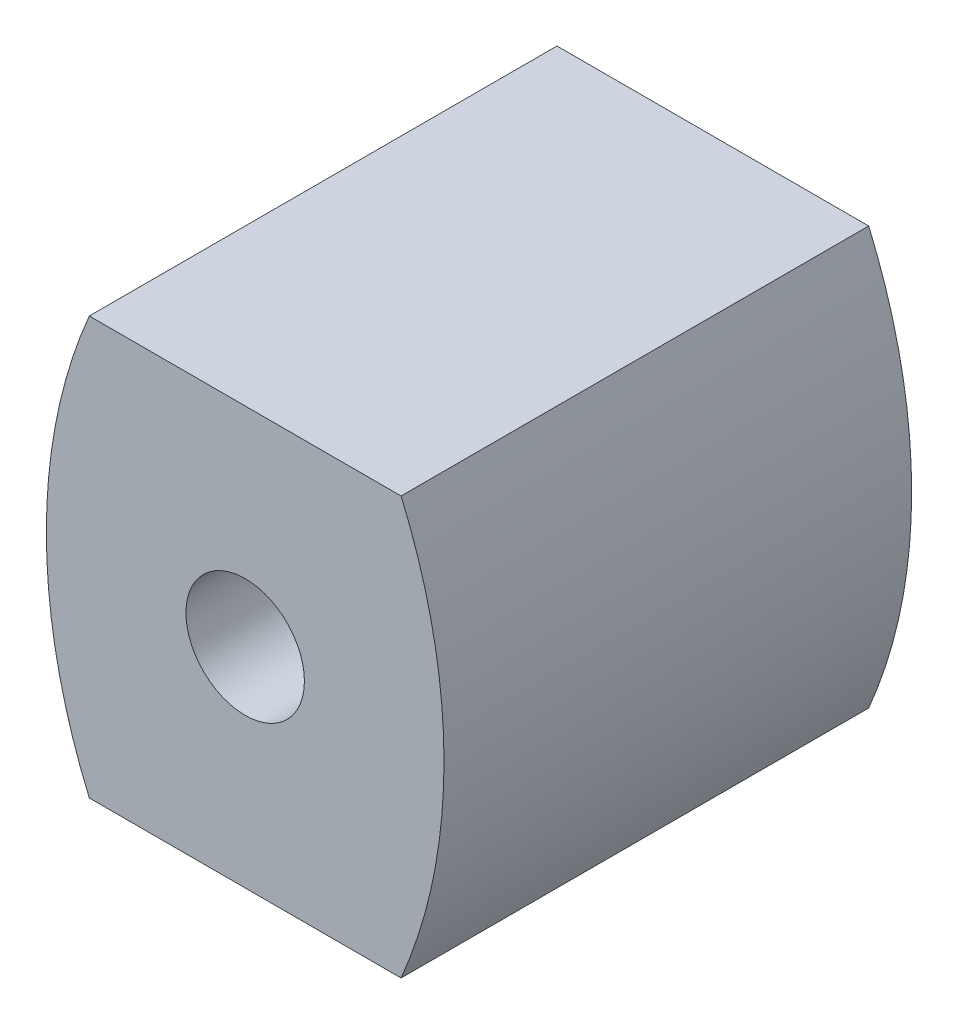
from build123d import *

# Parameters (mm, degrees)
CROQUIS1_R              = 1.9
SALIENTE_EXTRUIR2_DEPTH = 15


with BuildPart() as part:
    # Croquis1 → Saliente-Extruir2 (new body)
    with BuildSketch(Plane.XY):
        with BuildLine():
            ThreePointArc((-28.784956102, -9.143234849), (-27.407440411, -15.838234849), (-28.784956102, -22.533234849))
            Line((-28.784956102, -22.533234849), (-38.784956102, -22.533234849))
            ThreePointArc((-38.784956102, -22.533234849), (-40.162471794, -15.838234849), (-38.784956102, -9.143234849))
            Line((-38.784956102, -9.143234849), (-28.784956102, -9.143234849))
        make_face()
        with Locations((-33.784956102, -15.838234849)):
            Circle(CROQUIS1_R, mode=Mode.SUBTRACT)
    extrude(amount=SALIENTE_EXTRUIR2_DEPTH)


solid = part.part
